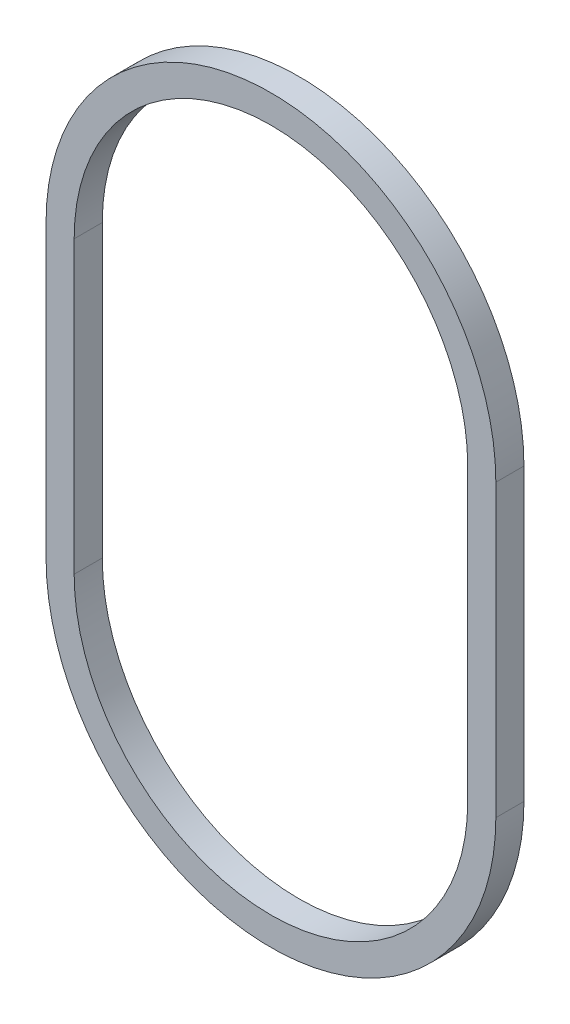
from build123d import *

# Parameters (mm, degrees)
BOSS_EXTRUDE1_DEPTH = 1.5


with BuildPart() as part:
    # Sketch1 → Boss-Extrude1 (new body, symmetric)
    with BuildSketch(Plane.XY):
        with BuildLine():
            Line((-24, -31), (-24, 0))
            ThreePointArc((-24, 0), (0, 24), (24, 0))
            Line((24, 0), (24, -31))
            ThreePointArc((24, -31), (0, -55), (-24, -31))
        make_face()
        with BuildLine():
            Line((-21, -31), (-21, 0))
            ThreePointArc((-21, 0), (0, 21), (21, 0))
            Line((21, 0), (21, -31))
            ThreePointArc((21, -31), (0, -52), (-21, -31))
        make_face(mode=Mode.SUBTRACT)
    extrude(amount=BOSS_EXTRUDE1_DEPTH, both=True)


solid = part.part
